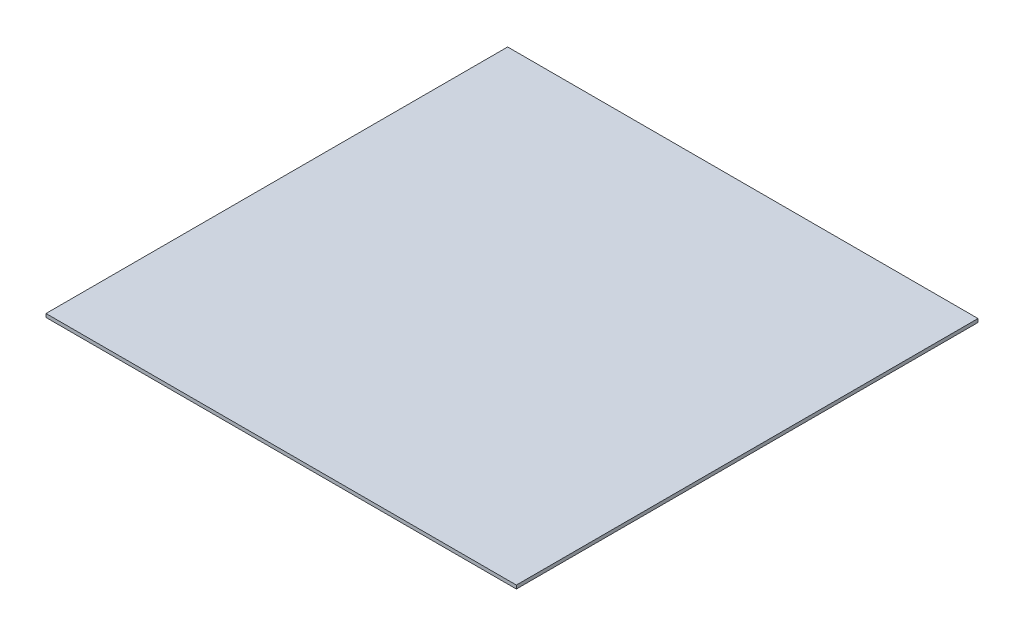
from build123d import *

# Parameters (mm, degrees)
SKETCH1_W           = 685.8
SKETCH1_H           = 673.1
BOSS_EXTRUDE1_DEPTH = 5.08


with BuildPart() as part:
    # Sketch1 → Boss-Extrude1 (new body)
    with BuildSketch(Plane(origin=(0, 0, 0), x_dir=(1, 0, 0), z_dir=(0, 1, 0))):
        with Locations((342.9, -336.55)):
            Rectangle(SKETCH1_W, SKETCH1_H)
    extrude(amount=BOSS_EXTRUDE1_DEPTH)


solid = part.part
